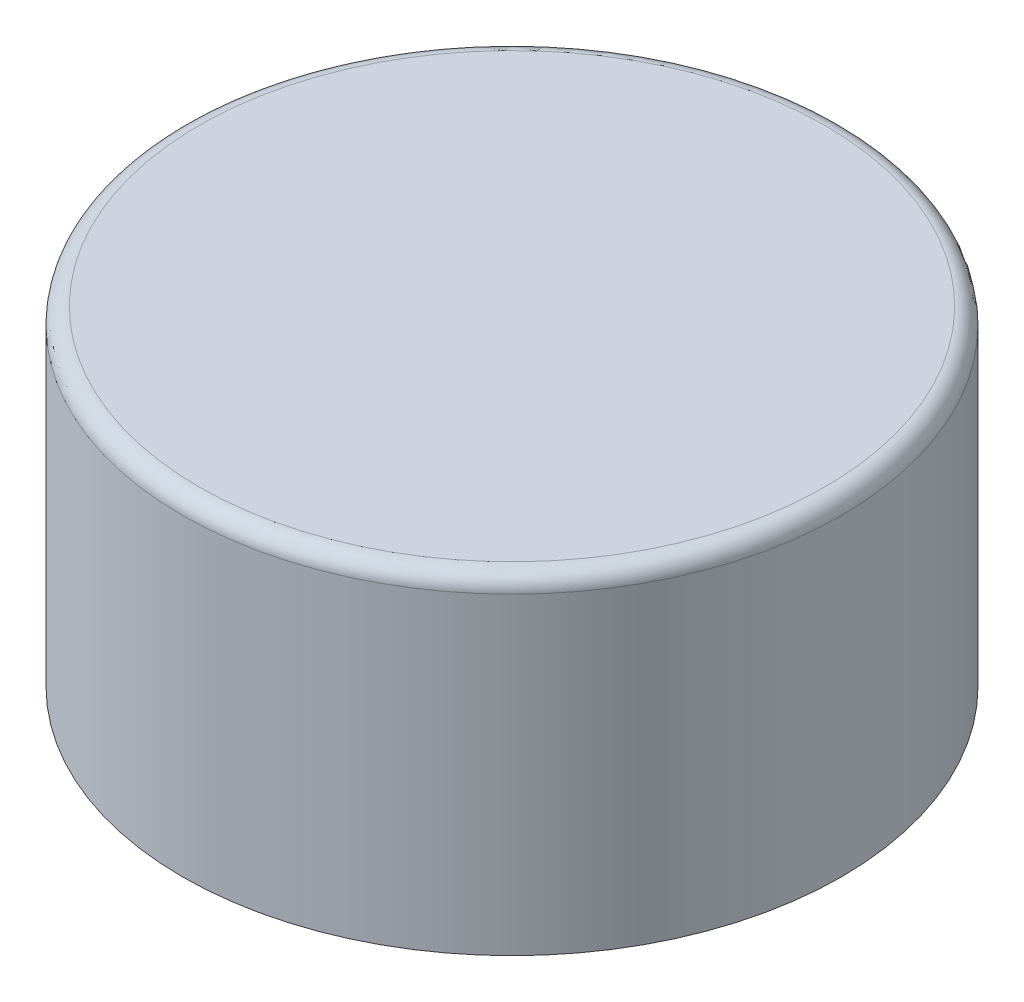
from build123d import *

# Parameters (mm, degrees)
SKETCH_1_R        = 40
EXTRUDE_1_DEPTH   = 40
FILLET_1_R        = 2
SWEEP_3_PROFILE_R = 0.75
SKETCH_2_W        = 0.5
SKETCH_2_H        = 1


with BuildPart() as part:
    # 草图1 → 凸台-拉伸1 (new body)
    with BuildSketch(Plane(origin=(0, 0, 0), x_dir=(1, 0, 0), z_dir=(0, 1, 0))):
        Circle(SKETCH_1_R)
    extrude(amount=EXTRUDE_1_DEPTH)

    # 圆角1
    fillet_1_edges = [part.edges().sort_by_distance(p)[0] for p in [
        (-40, 40, 0),
    ]]
    fillet(fillet_1_edges, radius=FILLET_1_R)

    # 切除-扫描3: sweep along a path in 草图3
    with BuildLine(Plane.XZ) as sweep_3_path:
        CenterArc((0, 0), 9, 0, 360)
    # 切除-扫描3 profile (on start of the path) → 切除-扫描3 (sweep, cut)
    with BuildSketch(Plane(origin=(9, 0, 0), x_dir=(1, 0, 0), z_dir=(0, 0, 1))):
        Circle(SWEEP_3_PROFILE_R)
    sweep(path=sweep_3_path.line, mode=Mode.SUBTRACT)

    # 草图2 → 切除-旋转1 (revolve, cut)
    with BuildSketch(Plane.XY):
        with Locations((0.25, 0.5)):
            Rectangle(SKETCH_2_W, SKETCH_2_H)
    revolve(axis=Axis((0, 0, 0), (0, 1, 0)), mode=Mode.SUBTRACT)


solid = part.part
